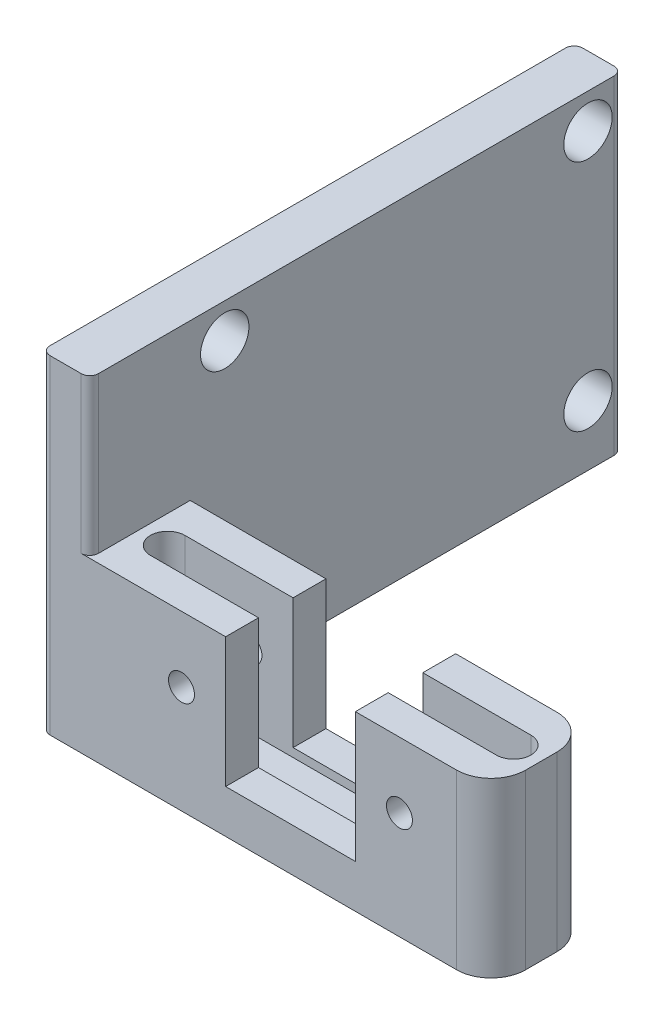
from build123d import *

# Parameters (mm, degrees)
EXTRUDE_1_DEPTH     = 19
SKETCH_3_W          = 23.2
SKETCH_3_H          = 9
CUT_EXTRUDE_2_DEPTH = 31.8
CUT_EXTRUDE_3_DEPTH = 8
SKETCH_5_W          = 7.5
SKETCH_5_H          = 7.5
CUT_EXTRUDE_4_DEPTH = 31.8
SKETCH_6_R          = 1.4
CUT_EXTRUDE_5_DEPTH = 27
SKETCH_7_R          = 0.75
CUT_EXTRUDE_6_DEPTH = 31.8
FILLET_2_R          = 0.5
FILLET_3_R          = 2
FILLET_4_R          = 0.5


with BuildPart() as part:
    # 草图1 → 凸台-拉伸1 (new body)
    with BuildSketch(Plane(origin=(0, 0, 0), x_dir=(1, 0, 0), z_dir=(0, 1, 0))):
        Polygon((-5.22, 18.4025), (-2.42, 18.4025), (-2.42, -6.5975), (20.78, -6.5975), (20.78, -12.3975), (-5.22, -12.3975), align=None)
    extrude(amount=EXTRUDE_1_DEPTH)

    # 草图3 → 切除-拉伸2 (cut, through all)
    with BuildSketch(Plane.XY.offset(12.3975)):
        with Locations((9.18, 14.5)):
            Rectangle(SKETCH_3_W, SKETCH_3_H)
    extrude(amount=-CUT_EXTRUDE_2_DEPTH, mode=Mode.SUBTRACT)

    # 草图4 → 切除-拉伸3 (cut)
    with BuildSketch(Plane(origin=(0, 10, 0), x_dir=(1, 0, 0), z_dir=(0, 1, 0))):
        with BuildLine():
            Line((-0.82, -8.4975), (19.18, -8.4975))
            ThreePointArc((19.18, -8.4975), (20.18, -9.4975), (19.18, -10.4975))
            Line((19.18, -10.4975), (-0.82, -10.4975))
            ThreePointArc((-0.82, -10.4975), (-1.82, -9.4975), (-0.82, -8.4975))
        make_face()
    extrude(amount=-CUT_EXTRUDE_3_DEPTH, mode=Mode.SUBTRACT)

    # 草图5 → 切除-拉伸4 (cut, through all)
    with BuildSketch(Plane.XY.offset(12.3975)):
        with Locations((9.18, 6.25)):
            Rectangle(SKETCH_5_W, SKETCH_5_H)
    extrude(amount=-CUT_EXTRUDE_4_DEPTH, mode=Mode.SUBTRACT)

    # 草图6 → 切除-拉伸5 (cut, through all)
    with BuildSketch(Plane.ZY.offset(5.22)):
        with Locations((-16.4025, 17)):
            Circle(SKETCH_6_R)
        with Locations((4.5975, 17)):
            Circle(SKETCH_6_R)
        with Locations((-16.4025, 3.5)):
            Circle(SKETCH_6_R)
        with Locations((4.5975, 3.5)):
            Circle(SKETCH_6_R)
    extrude(amount=-CUT_EXTRUDE_5_DEPTH, mode=Mode.SUBTRACT)

    # 草图7 → 切除-拉伸6 (cut, through all)
    with BuildSketch(Plane.XY.offset(12.3975)):
        with Locations((2.88, 6.2)):
            Circle(SKETCH_7_R)
        with Locations((15.48, 6.2)):
            Circle(SKETCH_7_R)
    extrude(amount=-CUT_EXTRUDE_6_DEPTH, mode=Mode.SUBTRACT)

    # 圆角2
    fillet_2_edges = [part.edges().sort_by_distance(p)[0] for p in [
        (-5.22, 9.5, -18.4025),
        (-2.42, 9.5, -18.4025),
        (-5.22, 9.5, 12.3975),
    ]]
    fillet(fillet_2_edges, radius=FILLET_2_R)

    # 圆角3
    fillet_3_edges = [part.edges().sort_by_distance(p)[0] for p in [
        (20.78, 5, 6.5975),
        (20.78, 5, 12.3975),
    ]]
    fillet(fillet_3_edges, radius=FILLET_3_R)

    # 圆角4
    fillet_4_edges = [part.edges().sort_by_distance(p)[0] for p in [
        (-2.42, 14.5, 12.3975),
    ]]
    fillet(fillet_4_edges, radius=FILLET_4_R)


solid = part.part
